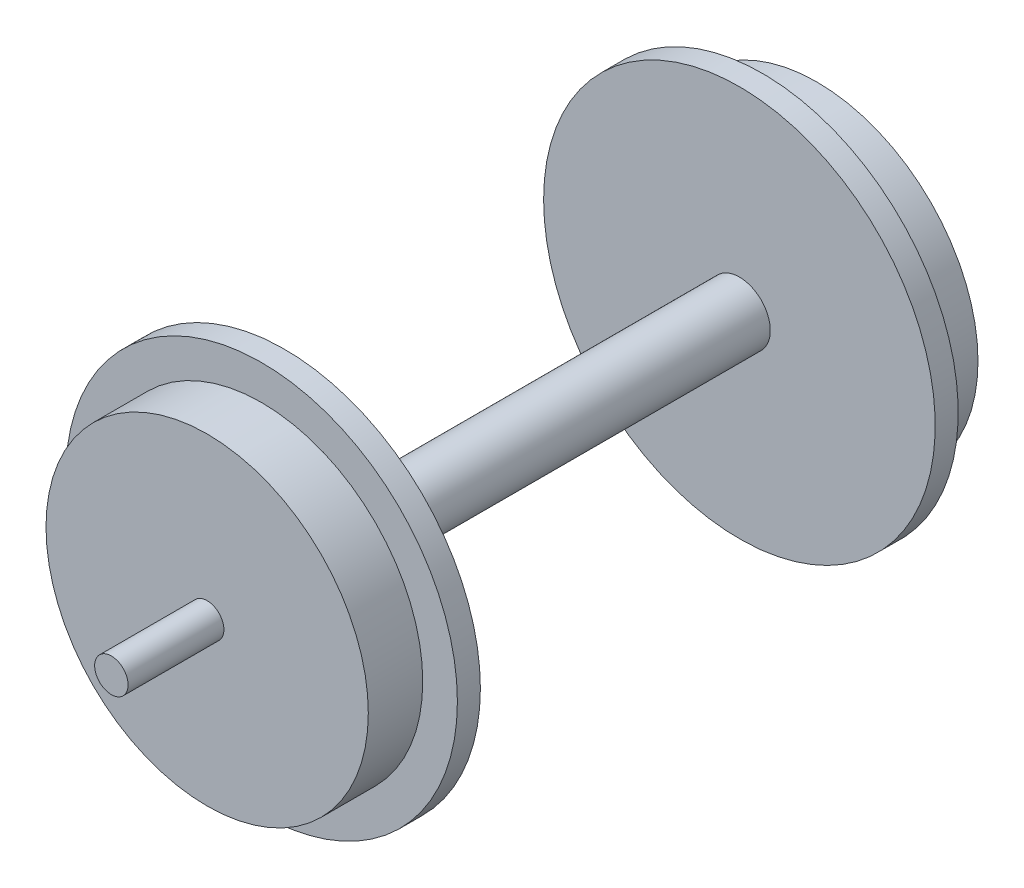
from build123d import *

# Parameters (mm, degrees)
SKETCH1_R           = 17.375
BOSS_EXTRUDE1_DEPTH = 2.04
SKETCH2_R           = 14.3
BOSS_EXTRUDE2_DEPTH = 4.83
SKETCH3_R           = 2.74
BOSS_EXTRUDE3_DEPTH = 40.36
SKETCH4_R           = 17.375
BOSS_EXTRUDE4_DEPTH = 2.04
SKETCH5_R           = 14.3
BOSS_EXTRUDE5_DEPTH = 4.83
SKETCH6_R           = 1.485
BOSS_EXTRUDE6_DEPTH = 8.5
SKETCH7_R           = 1.485
BOSS_EXTRUDE7_DEPTH = 8.5


with BuildPart() as part:
    # Sketch1 → Boss-Extrude1 (new body)
    with BuildSketch(Plane.XY):
        Circle(SKETCH1_R)
    extrude(amount=BOSS_EXTRUDE1_DEPTH)

    # Sketch2 → Boss-Extrude2 (add)
    with BuildSketch(Plane.XY.offset(2.04)):
        Circle(SKETCH2_R)
    extrude(amount=BOSS_EXTRUDE2_DEPTH)

    # Sketch3 → Boss-Extrude3 (add)
    with BuildSketch(Plane(origin=(0, 0, 0), x_dir=(-1, 0, 0), z_dir=(0, 0, -1))):
        Circle(SKETCH3_R)
    extrude(amount=BOSS_EXTRUDE3_DEPTH)

    # Sketch4 → Boss-Extrude4 (add)
    with BuildSketch(Plane(origin=(0, 0, -40.36), x_dir=(-1, 0, 0), z_dir=(0, 0, -1))):
        Circle(SKETCH4_R)
    extrude(amount=BOSS_EXTRUDE4_DEPTH)

    # Sketch5 → Boss-Extrude5 (add)
    with BuildSketch(Plane(origin=(0, 0, -42.4), x_dir=(-1, 0, 0), z_dir=(0, 0, -1))):
        Circle(SKETCH5_R)
    extrude(amount=BOSS_EXTRUDE5_DEPTH)

    # Sketch6 → Boss-Extrude6 (add)
    with BuildSketch(Plane(origin=(0, 0, -47.23), x_dir=(-1, 0, 0), z_dir=(0, 0, -1))):
        Circle(SKETCH6_R)
    extrude(amount=BOSS_EXTRUDE6_DEPTH)

    # Sketch7 → Boss-Extrude7 (add)
    with BuildSketch(Plane.XY.offset(6.87)):
        Circle(SKETCH7_R)
    extrude(amount=BOSS_EXTRUDE7_DEPTH)


solid = part.part
